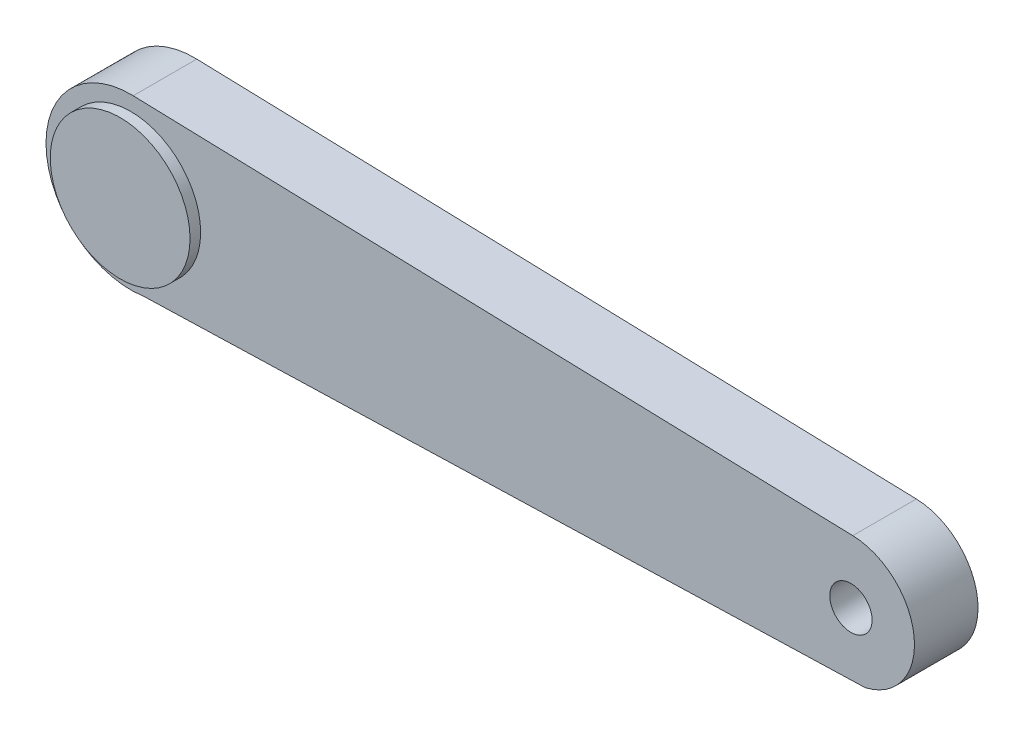
from build123d import *

# Parameters (mm, degrees)
BOSS_EXTRUDE1_DEPTH = 7.5
SKETCH3_R           = 16.5
BOSS_EXTRUDE2_DEPTH = 2.5
SKETCH6_R           = 5
CUT_EXTRUDE1_DEPTH  = 10
SKETCH7_R           = 5
BOSS_EXTRUDE3_DEPTH = 10


with BuildPart() as part:
    # Sketch1 → Boss-Extrude1 (new body, symmetric)
    with BuildSketch(Plane.XY):
        with BuildLine():
            Line((-81.983854392, -19.771263634), (88.350129521, -14.621102291))
            ThreePointArc((88.350129521, -14.621102291), (99.92815548, 1.466347152), (85.441176471, 14.993510707))
            Line((85.441176471, 14.993510707), (-84.411764706, 19.991347609))
            ThreePointArc((-84.411764706, 19.991347609), (-104.962820533, -1.218932468), (-81.983854392, -19.771263634))
        make_face()
    extrude(amount=BOSS_EXTRUDE1_DEPTH, both=True)

    # Sketch3 → Boss-Extrude2 (add, symmetric)
    with BuildSketch(Plane.XY.offset(7.5)):
        with Locations((-85, 0)):
            Circle(SKETCH3_R)
    extrude(amount=BOSS_EXTRUDE2_DEPTH, both=True)

    # Sketch6 → Cut-Extrude1 (cut)
    with BuildSketch(Plane.XY.offset(7.5)):
        with Locations((85, 0)):
            Circle(SKETCH6_R)
    extrude(amount=-CUT_EXTRUDE1_DEPTH, mode=Mode.SUBTRACT)

    # Sketch7 → Boss-Extrude3 (add)
    with BuildSketch(Plane(origin=(0, 0, -7.5), x_dir=(-1, 0, 0), z_dir=(0, 0, -1))):
        with Locations((85, 0)):
            Circle(SKETCH7_R)
    extrude(amount=BOSS_EXTRUDE3_DEPTH)


solid = part.part
